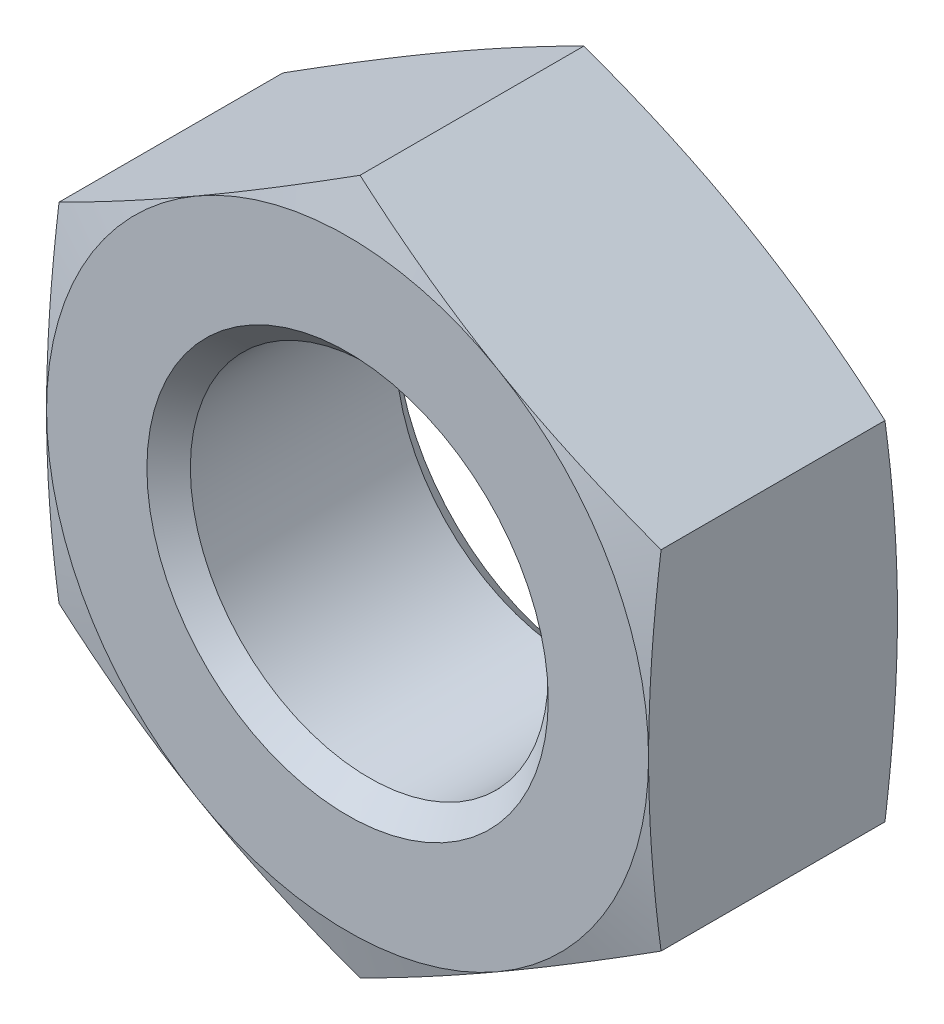
from build123d import *

# Parameters (mm, degrees)
SKETCH2_W          = 38.1
SKETCH2_H          = 38.1
CUT_EXTRUDE1_DEPTH = 7.874


with BuildPart() as part:
    # Sketch1 → Revolve1 (revolve)
    with BuildSketch(Plane(origin=(0, 0, 0), x_dir=(0, 0, -1), z_dir=(1, 0, 0))):
        Polygon((0, 0), (0, 9.525), (0.510443212, 11.43), (7.363556788, 11.43), (7.874, 9.525), (7.874, 0), align=None)
    revolve(axis=Axis((0, 0, -7.874), (0, 0, 1)))

    # Sketch2 → Cut-Extrude1 (cut)
    with BuildSketch(Plane.XY):
        Rectangle(SKETCH2_W, SKETCH2_H)
        Polygon((-9.525, 5.499261314), (-9.525, -5.499261314), (0, -10.998522628), (9.525, -5.499261314), (9.525, 5.499261314), (0, 10.998522628), align=None, mode=Mode.SUBTRACT)
    extrude(amount=-CUT_EXTRUDE1_DEPTH, mode=Mode.SUBTRACT)

    # Sketch3 → Cut-Revolve1 (revolve, cut)
    with BuildSketch(Plane(origin=(0, 0, 0), x_dir=(0, 0, -1), z_dir=(1, 0, 0))):
        Polygon((0, 0), (0, 6.35), (0.68707, 5.66293), (7.18693, 5.66293), (7.874, 6.35), (7.874, 0), align=None)
    revolve(axis=Axis((0, 0, -7.874), (0, 0, 1)), mode=Mode.SUBTRACT)


solid = part.part
